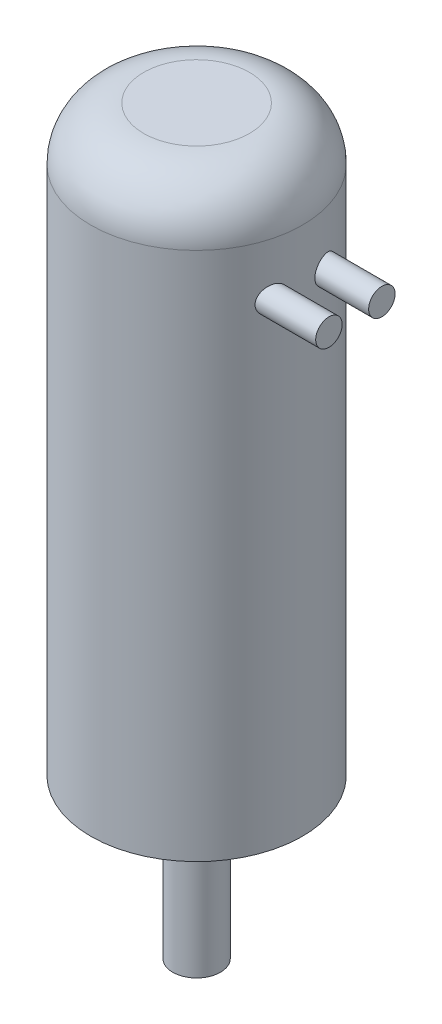
from build123d import *

# Parameters (mm, degrees)
SKETCH1_R           = 20
BOSS_EXTRUDE1_DEPTH = 110
SKETCH2_R           = 3
CUT_EXTRUDE1_DEPTH  = 25
SKETCH3_R           = 4.5
BOSS_EXTRUDE2_DEPTH = 30
FILLET1_R           = 10
BOSS_EXTRUDE3_REACH = 52
SKETCH4_R           = 2.5


with BuildPart() as part:
    # Sketch1 → Boss-Extrude1 (new body)
    with BuildSketch(Plane(origin=(0, 0, 0), x_dir=(1, 0, 0), z_dir=(0, 1, 0))):
        Circle(SKETCH1_R)
    extrude(amount=BOSS_EXTRUDE1_DEPTH)

    # Sketch2 → Cut-Extrude1 (cut)
    with BuildSketch(Plane(origin=(0, 0, 0), x_dir=(1, 0, 0), z_dir=(0, 1, 0))):
        with Locations((15, 0)):
            Circle(SKETCH2_R)
        with Locations((-15, 0)):
            Circle(SKETCH2_R)
    extrude(amount=CUT_EXTRUDE1_DEPTH, mode=Mode.SUBTRACT)

    # Sketch3 → Boss-Extrude2 (add)
    with BuildSketch(Plane(origin=(0, 0, 0), x_dir=(1, 0, 0), z_dir=(0, 1, 0))):
        Circle(SKETCH3_R)
    extrude(amount=-BOSS_EXTRUDE2_DEPTH)

    # Fillet1
    fillet1_edges = [part.edges().sort_by_distance(p)[0] for p in [
        (-20, 110, 0),
    ]]
    fillet(fillet1_edges, radius=FILLET1_R)

    # Sketch4 → Boss-Extrude3 (add, up to next)
    with BuildSketch(Plane(origin=(30, 0, 0), x_dir=(0, 0, -1), z_dir=(1, 0, 0)), mode=Mode.PRIVATE) as boss_extrude3_sk1:
        with Locations((5, 90)):
            Circle(SKETCH4_R)
    boss_extrude3_tool1 = extrude(boss_extrude3_sk1.sketch, amount=-BOSS_EXTRUDE3_REACH, mode=Mode.PRIVATE) - part.part
    add(boss_extrude3_tool1.solids().sort_by_distance((30, 90, -5))[0])
    # Sketch4 → Boss-Extrude3 (add, up to next)
    with BuildSketch(Plane(origin=(30, 0, 0), x_dir=(0, 0, -1), z_dir=(1, 0, 0)), mode=Mode.PRIVATE) as boss_extrude3_sk2:
        with Locations((-5, 90)):
            Circle(SKETCH4_R)
    boss_extrude3_tool2 = extrude(boss_extrude3_sk2.sketch, amount=-BOSS_EXTRUDE3_REACH, mode=Mode.PRIVATE) - part.part
    add(boss_extrude3_tool2.solids().sort_by_distance((30, 90, 5))[0])


solid = part.part
